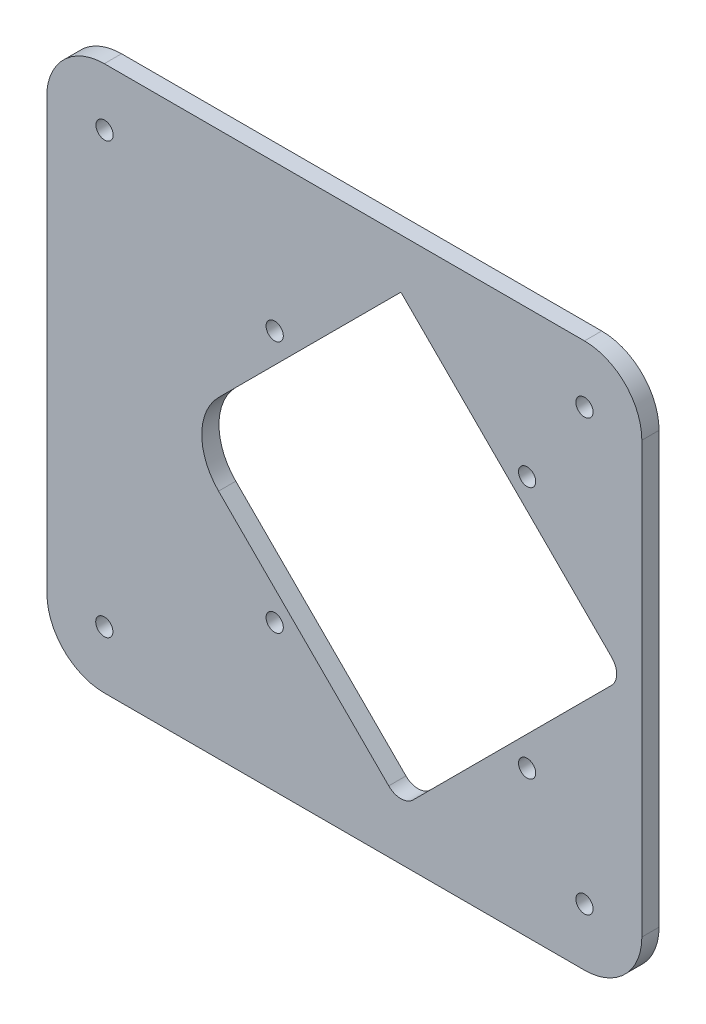
from build123d import *

# Parameters (mm, degrees)
MODEL_R             = 1.499994887
BOSS_EXTRUDE1_DEPTH = 3


with BuildPart() as part:
    # Model → Boss-Extrude1 (new body)
    with BuildSketch(Plane.XY):
        with BuildLine():
            ThreePointArc((127.267167807, 75.815864008), (124.338313147, 82.886904548), (117.267301896, 85.815829919))
            Line((117.267301896, 85.815829919), (33.567587225, 85.815829919))
            ThreePointArc((33.567587225, 85.815829919), (26.851651545, 83.222459398), (23.567621314, 76.815860599))
            Line((23.567621314, 76.815860599), (23.567621314, 67.211322932))
            Line((23.567621314, 67.211322932), (23.567621314, 11.790716994))
            Line((23.567621314, 11.790716994), (23.567621314, 0.81611968))
            ThreePointArc((23.567621314, 0.81611968), (26.49658283, -6.254927716), (33.567648038, -9.183846231))
            Line((33.567648038, -9.183846231), (117.267301896, -9.183846231))
            ThreePointArc((117.267301896, -9.183846231), (124.338288146, -6.25489586), (127.267167807, 0.816119679))
            Line((127.267167807, 0.816119679), (127.267167807, 11.594182037))
            Line((127.267167807, 11.594182037), (127.267167807, 49.315954345))
            Line((127.267167807, 49.315954345), (127.267167807, 75.815864008))
        make_face()
        with Locations((33.567587225, 0.816119679)):
            Circle(MODEL_R, mode=Mode.SUBTRACT)
        with Locations((63.267605432, 16.315947389)):
            Circle(MODEL_R, mode=Mode.SUBTRACT)
        with Locations((117.267226438, 0.816095138)):
            Circle(MODEL_R, mode=Mode.SUBTRACT)
        with Locations((107.26755543, 16.315947389)):
            Circle(MODEL_R, mode=Mode.SUBTRACT)
        with Locations((63.267555431, 60.315947389)):
            Circle(MODEL_R, mode=Mode.SUBTRACT)
        with Locations((33.610039072, 75.815864008)):
            Circle(MODEL_R, mode=Mode.SUBTRACT)
        with BuildLine():
            Line((53.483284952, 45.387404724), (75.735868353, 67.640059648))
            Line((75.735868353, 67.640059648), (82.064163104, 73.968374739))
            Line((82.064163104, 73.968374739), (85.267424216, 77.171646146))
            Line((85.267424216, 77.171646146), (89.463558538, 72.975511824))
            Line((89.463558538, 72.975511824), (122.001384869, 40.437685493))
            ThreePointArc((122.001384869, 40.437685493), (122.88006153, 38.316372381), (122.001384869, 36.195059268))
            Line((122.001384869, 36.195059268), (87.388740737, 1.582415136))
            ThreePointArc((87.388740737, 1.582415136), (85.267425214, 0.703738475), (83.146111103, 1.582418545))
            Line((83.146111103, 1.582418545), (53.483284952, 31.245340037))
            ThreePointArc((53.483284952, 31.245340037), (50.554374112, 38.316372381), (53.483284952, 45.387404724))
        make_face(mode=Mode.SUBTRACT)
        with Locations((107.26755543, 60.315797391)):
            Circle(MODEL_R, mode=Mode.SUBTRACT)
        with Locations((117.267226438, 75.815864008)):
            Circle(MODEL_R, mode=Mode.SUBTRACT)
    extrude(amount=BOSS_EXTRUDE1_DEPTH)


solid = part.part
